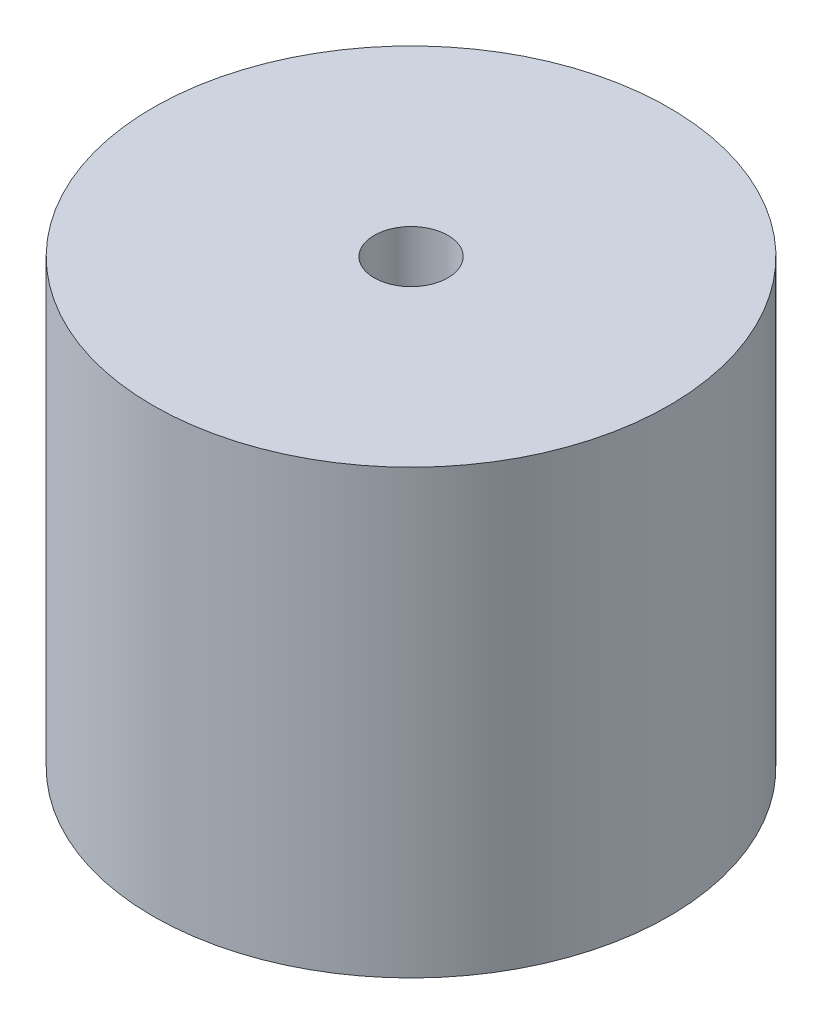
from build123d import *

# Parameters (mm, degrees)
SKETCH1_R           = 22.225
SKETCH1_R_2         = 3.175
BOSS_EXTRUDE1_DEPTH = 38.1


with BuildPart() as part:
    # Sketch1 → Boss-Extrude1 (new body)
    with BuildSketch(Plane(origin=(0, 0, 0), x_dir=(1, 0, 0), z_dir=(0, 1, 0))):
        Circle(SKETCH1_R)
        Circle(SKETCH1_R_2, mode=Mode.SUBTRACT)
    extrude(amount=BOSS_EXTRUDE1_DEPTH)


solid = part.part
